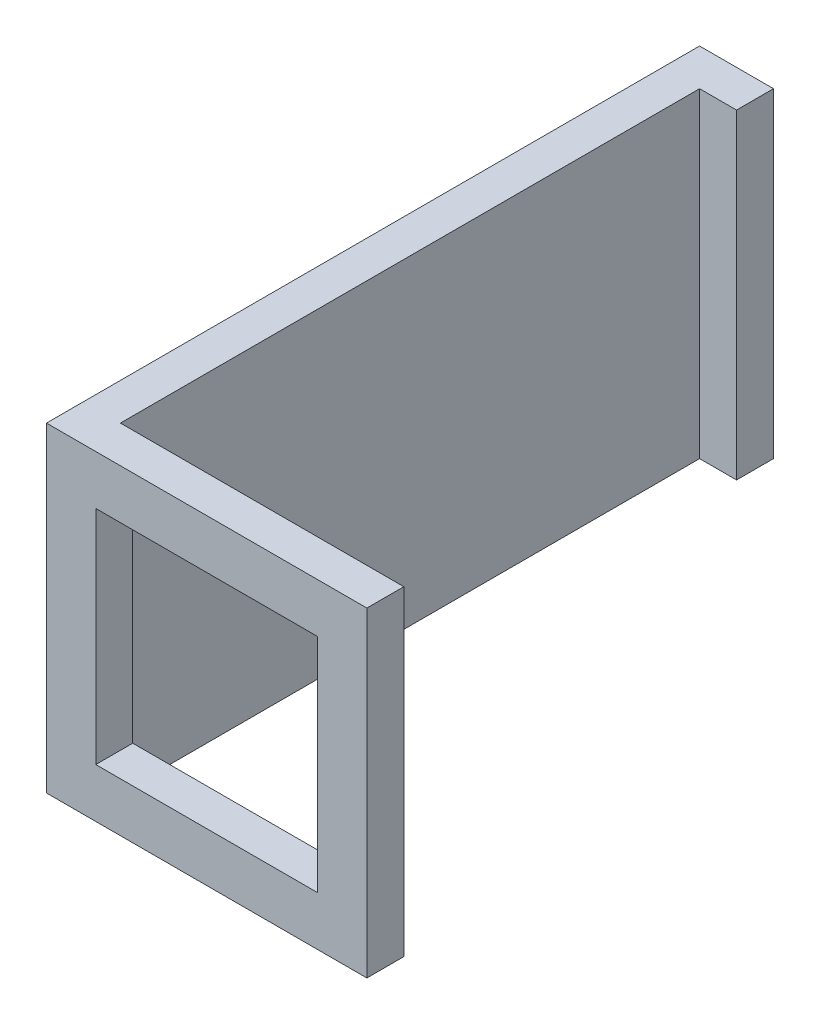
from build123d import *

# Parameters (mm, degrees)
SKETCH1_W           = 13
SKETCH1_H           = 13
SKETCH1_W_2         = 9
SKETCH1_H_2         = 9
BOSS_EXTRUDE1_DEPTH = 1.5
SKETCH2_W           = 1.5
SKETCH2_H           = 13
BOSS_EXTRUDE2_DEPTH = 25
SKETCH3_W           = 1.5
SKETCH3_H           = 13
BOSS_EXTRUDE3_DEPTH = 1.5


with BuildPart() as part:
    # Sketch1 → Boss-Extrude1 (new body)
    with BuildSketch(Plane.XY):
        Rectangle(SKETCH1_W, SKETCH1_H)
        Rectangle(SKETCH1_W_2, SKETCH1_H_2, mode=Mode.SUBTRACT)
    extrude(amount=BOSS_EXTRUDE1_DEPTH)

    # Sketch2 → Boss-Extrude2 (add)
    with BuildSketch(Plane(origin=(0, 0, 0), x_dir=(-1, 0, 0), z_dir=(0, 0, -1))):
        with Locations((5.75, 0)):
            Rectangle(SKETCH2_W, SKETCH2_H)
    extrude(amount=BOSS_EXTRUDE2_DEPTH)

    # Sketch3 → Boss-Extrude3 (add)
    with BuildSketch(Plane(origin=(-5, 0, 0), x_dir=(0, 0, -1), z_dir=(1, 0, 0))):
        with Locations((24.25, 0)):
            Rectangle(SKETCH3_W, SKETCH3_H)
    extrude(amount=BOSS_EXTRUDE3_DEPTH)


solid = part.part
